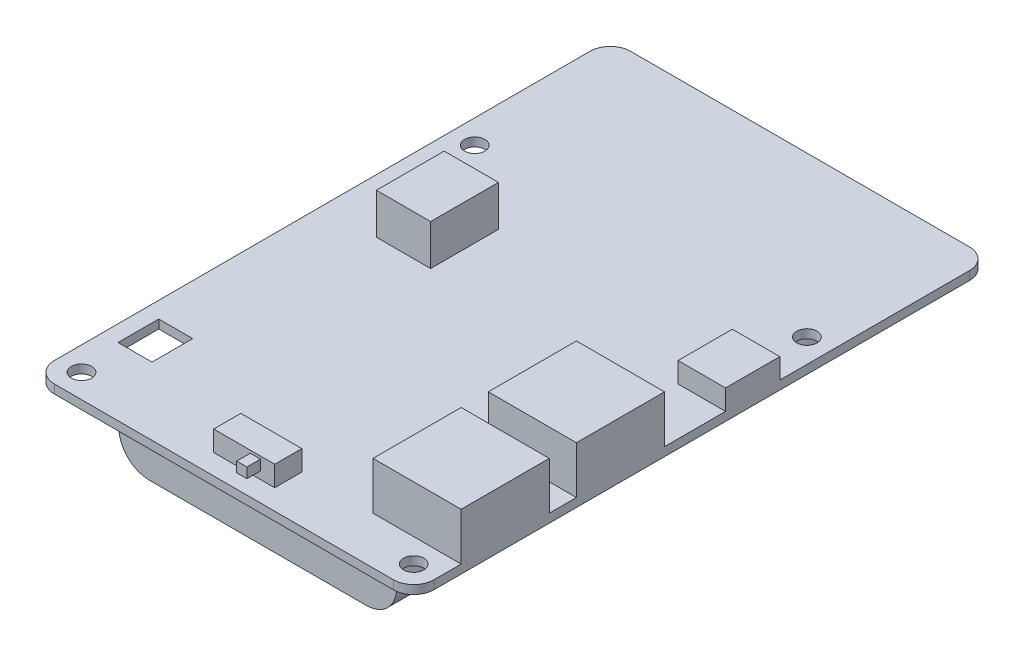
from build123d import *

# Parameters (mm, degrees)
SKETCH_1_W          = 56
SKETCH_1_H          = 85
SKETCH_1_R          = 1.5
EXTRUDE_1_DEPTH     = 1.28
FILLET_1_R          = 3
SKETCH_6_W          = 5
SKETCH_6_H          = 6
CUT_EXTRUDE_1_DEPTH = 2.28
SKETCH_4_W          = 8
SKETCH_4_H          = 10
EXTRUDE_2_DEPTH     = 6
SKETCH_5_W          = 9
SKETCH_5_H          = 4
EXTRUDE_3_DEPTH     = 3
SKETCH_2_W          = 13
SKETCH_2_H          = 13
EXTRUDE_4_DEPTH     = 7
SKETCH_3_W          = 7
SKETCH_3_H          = 8
EXTRUDE_5_DEPTH     = 3
SKETCH_7_W          = 1.5
SKETCH_7_H          = 1.5
EXTRUDE_6_DEPTH     = 2
EXTRUDE_START       = 37.5
EXTRUDE_8_DEPTH     = 67


with BuildPart() as part:
    # 草圖1 → 填料-伸長1 (new body)
    with BuildSketch(Plane(origin=(0, 0, 0), x_dir=(1, 0, 0), z_dir=(0, 1, 0))):
        Rectangle(SKETCH_1_W, SKETCH_1_H)
        with Locations((-24.5, 19)):
            Circle(SKETCH_1_R, mode=Mode.SUBTRACT)
        with Locations((-24.5, -39)):
            Circle(SKETCH_1_R, mode=Mode.SUBTRACT)
        with Locations((24.5, -39)):
            Circle(SKETCH_1_R, mode=Mode.SUBTRACT)
        with Locations((24.5, 19)):
            Circle(SKETCH_1_R, mode=Mode.SUBTRACT)
    extrude(amount=EXTRUDE_1_DEPTH)

    # 圓角1
    fillet_1_edges = [part.edges().sort_by_distance(p)[0] for p in [
        (28, 0.64, 42.5),
        (-28, 0.64, 42.5),
        (-28, 0.64, -42.5),
        (28, 0.64, -42.5),
    ]]
    fillet(fillet_1_edges, radius=FILLET_1_R)

    # 草圖6 → 除料-伸長1 (cut, through all)
    with BuildSketch(Plane(origin=(0, 1.28, 0), x_dir=(1, 0, 0), z_dir=(0, 1, 0))):
        with Locations((-23.1, -29.5)):
            Rectangle(SKETCH_6_W, SKETCH_6_H)
    extrude(amount=-CUT_EXTRUDE_1_DEPTH, mode=Mode.SUBTRACT)

    # 草圖4 → 填料-伸長2 (add)
    with BuildSketch(Plane(origin=(0, 1.28, 0), x_dir=(1, 0, 0), z_dir=(0, 1, 0))):
        with Locations((-16, 5)):
            Rectangle(SKETCH_4_W, SKETCH_4_H)
    extrude(amount=EXTRUDE_2_DEPTH)

    # 草圖5 → 填料-伸長3 (add)
    with BuildSketch(Plane(origin=(0, 1.28, 0), x_dir=(1, 0, 0), z_dir=(0, 1, 0))):
        with Locations((0, -37.5)):
            Rectangle(SKETCH_5_W, SKETCH_5_H)
    extrude(amount=EXTRUDE_3_DEPTH)

    # 草圖2 → 填料-伸長4 (add)
    with BuildSketch(Plane(origin=(0, 1.28, 0), x_dir=(1, 0, 0), z_dir=(0, 1, 0))):
        with Locations((21.5, -12)):
            Rectangle(SKETCH_2_W, SKETCH_2_H)
        with Locations((21.5, -29)):
            Rectangle(SKETCH_2_W, SKETCH_2_H)
    extrude(amount=EXTRUDE_4_DEPTH)

    # 草圖3 → 填料-伸長5 (add)
    with BuildSketch(Plane(origin=(0, 1.28, 0), x_dir=(1, 0, 0), z_dir=(0, 1, 0))):
        with Locations((24.5, 7.5)):
            Rectangle(SKETCH_3_W, SKETCH_3_H)
    extrude(amount=EXTRUDE_5_DEPTH)

    # 草圖7 → 填料-伸長6 (add)
    with BuildSketch(Plane.XY.offset(39.5)):
        with Locations((1.65, 3.13)):
            Rectangle(SKETCH_7_W, SKETCH_7_H)
    extrude(amount=EXTRUDE_6_DEPTH)

    # 草圖9 → 填料-伸長8 (add)
    with BuildSketch(Plane.XY.offset(EXTRUDE_START)):
        with BuildLine():
            Line((-16, 0), (16, 0))
            ThreePointArc((16, 0), (20.5, -4.5), (16, -9))
            Line((16, -9), (-16, -9))
            ThreePointArc((-16, -9), (-20.5, -4.5), (-16, 0))
        make_face()
    extrude(amount=-EXTRUDE_8_DEPTH)


solid = part.part
